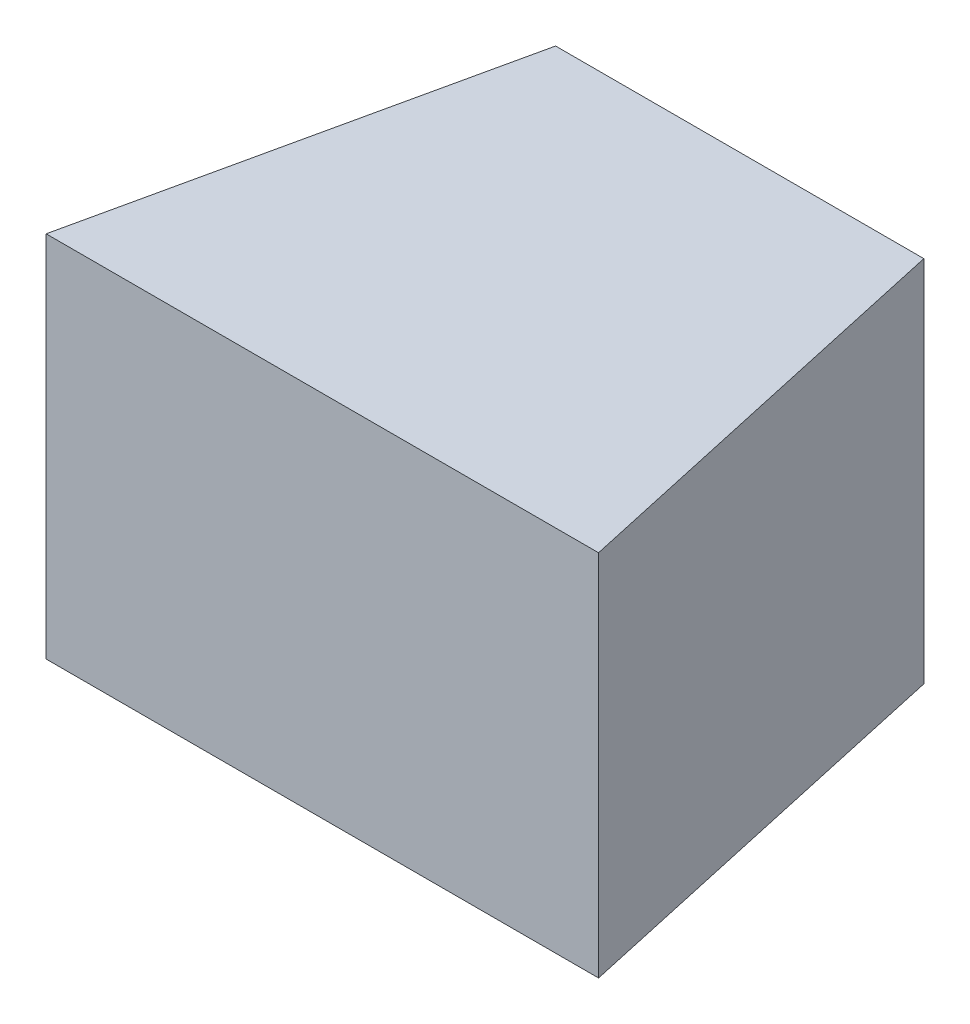
from build123d import *

# Parameters (mm, degrees)
EXTRUDE_1_DEPTH = 30


with BuildPart() as part:
    # 草圖1 → 填料-伸長1 (new body)
    with BuildSketch(Plane(origin=(0, 0, 0), x_dir=(1, 0, 0), z_dir=(0, 1, 0))):
        Polygon((-15, 17), (-22.5, -17), (22.5, -17), (15, 17), align=None)
    extrude(amount=EXTRUDE_1_DEPTH)


solid = part.part
